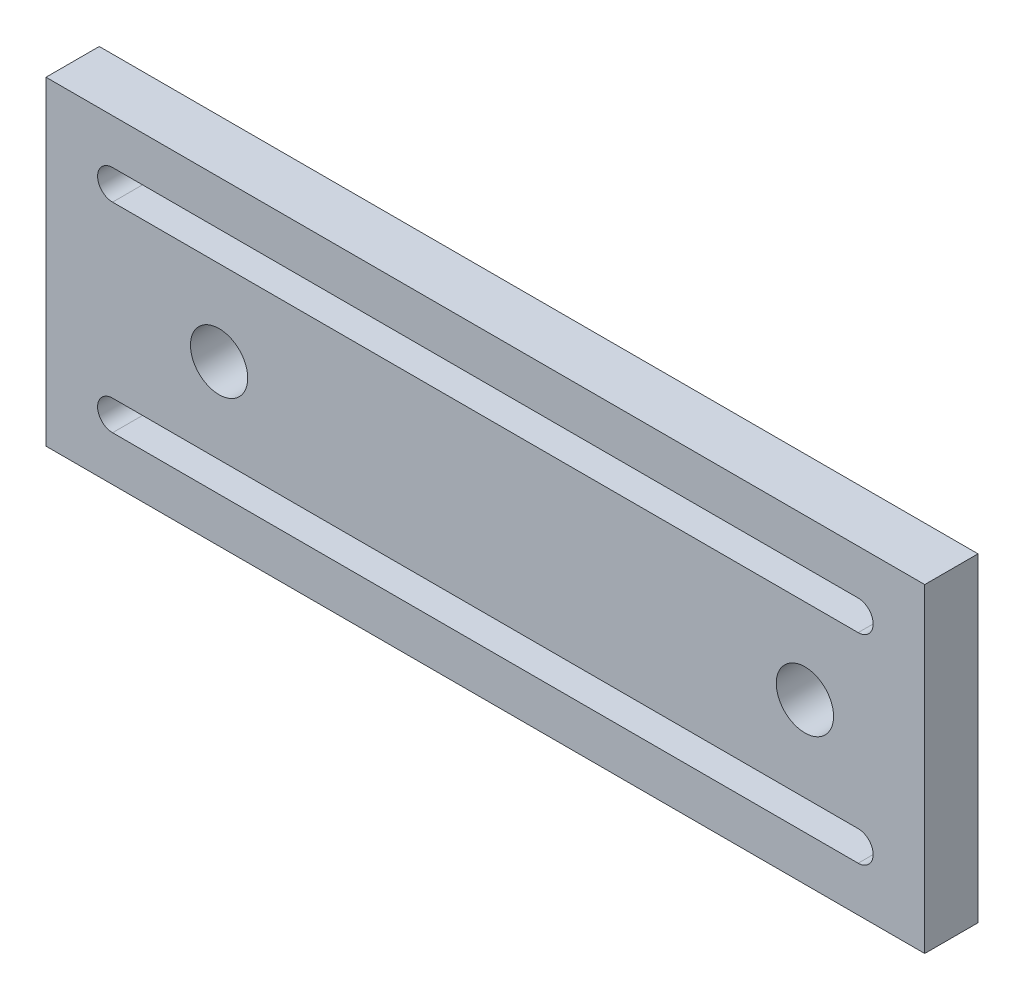
from build123d import *

# Parameters (mm, degrees)
SKETCH1_W           = 132
SKETCH1_H           = 48
SKETCH1_R           = 4.303275398
BOSS_EXTRUDE1_DEPTH = 8


with BuildPart() as part:
    # Sketch1 → Boss-Extrude1 (new body)
    with BuildSketch(Plane.XY):
        Rectangle(SKETCH1_W, SKETCH1_H)
        with Locations((-40, 0)):
            Circle(SKETCH1_R, mode=Mode.SUBTRACT)
        with Locations((48, 0)):
            Circle(SKETCH1_R, mode=Mode.SUBTRACT)
        with BuildLine():
            Line((56, 12.75), (-56, 12.75))
            ThreePointArc((-56, 12.75), (-58.25, 15), (-56, 17.25))
            Line((-56, 17.25), (56, 17.25))
            ThreePointArc((56, 17.25), (58.25, 15), (56, 12.75))
        make_face(mode=Mode.SUBTRACT)
        with BuildLine():
            Line((-56, -12.75), (56, -12.75))
            ThreePointArc((56, -12.75), (58.25, -15), (56, -17.25))
            Line((56, -17.25), (-56, -17.25))
            ThreePointArc((-56, -17.25), (-58.25, -15), (-56, -12.75))
        make_face(mode=Mode.SUBTRACT)
    extrude(amount=BOSS_EXTRUDE1_DEPTH)


solid = part.part
